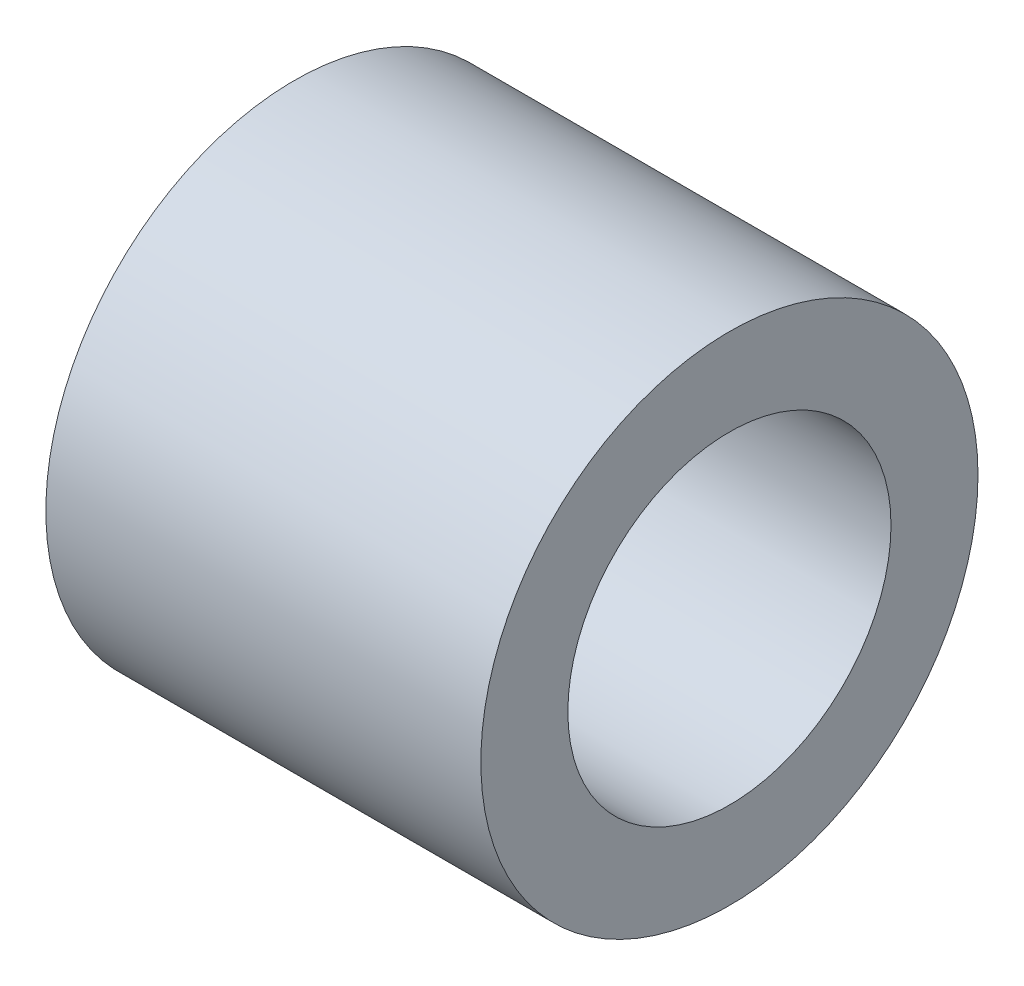
from build123d import *

# Parameters (mm, degrees)
SKETCH1_R           = 4
SKETCH1_R_2         = 2.6
BOSS_EXTRUDE1_DEPTH = 7


with BuildPart() as part:
    # Sketch1 → Boss-Extrude1 (new body)
    with BuildSketch(Plane(origin=(0, 0, 0), x_dir=(0, 0, -1), z_dir=(1, 0, 0))):
        Circle(SKETCH1_R)
        Circle(SKETCH1_R_2, mode=Mode.SUBTRACT)
    extrude(amount=BOSS_EXTRUDE1_DEPTH)


solid = part.part
